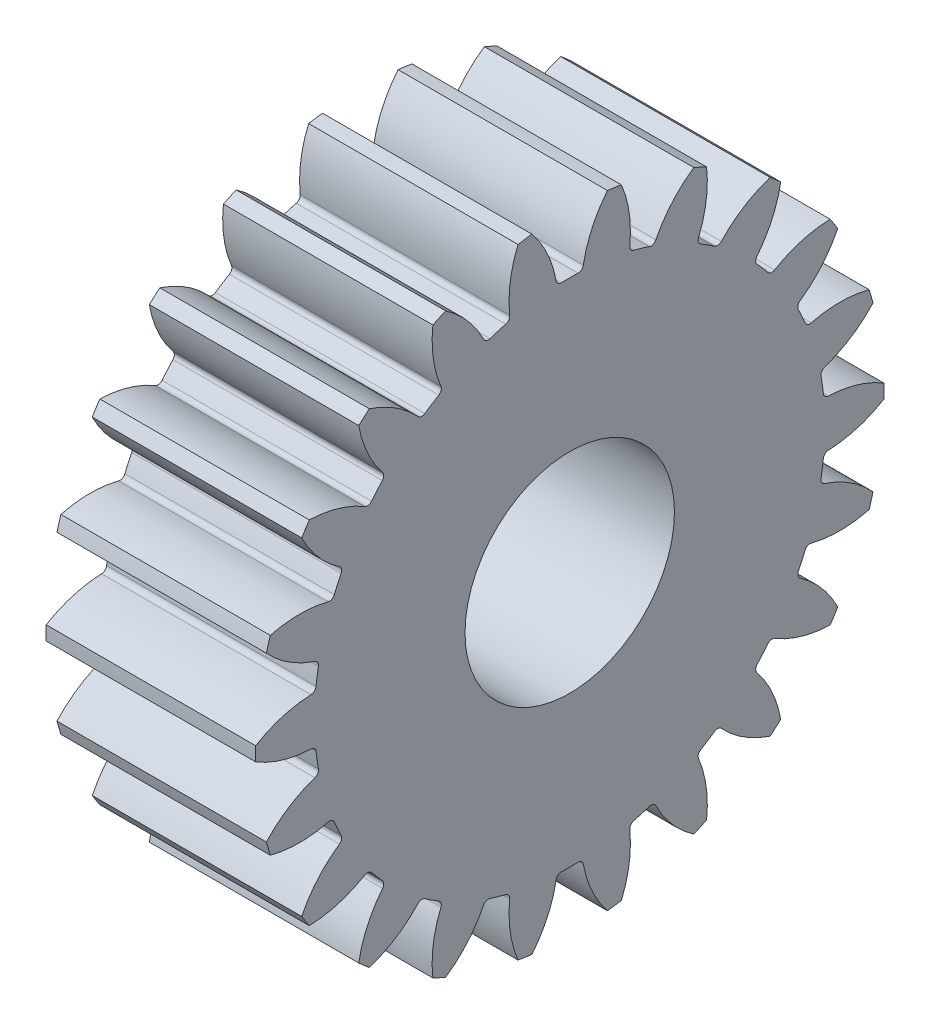
from build123d import *

# Parameters (mm, degrees)
BASPROSKE_W     = 4
BASPROSKE_H     = 6
TOOTHCUT_DEPTH  = 10.38083152
TEETHCUTS_COUNT = 22
TEETHCUTS_ANGLE = 343.636363636
BORSKE_R        = 2
BORE_DEPTH      = 50.0000508
FILLET1_R       = 0.1


with BuildPart() as part:
    # BasProSke → Base-Revolve (revolve)
    with BuildSketch(Plane(origin=(0, 0, 0), x_dir=(1, 0, 0), z_dir=(0, 1, 0)), mode=Mode.PRIVATE) as base_revolve_sk:
        with Locations((2, 3)):
            Rectangle(BASPROSKE_W, BASPROSKE_H)
    revolve(base_revolve_sk.sketch.rotate(Axis((-10, 0, 0), (1, 0, 0)), 180), axis=Axis((-10, 0, 0), (1, 0, 0)))

    # TooCutSke → ToothCut (cut, through all)
    with BuildSketch(Plane(origin=(0, 0, 0), x_dir=(0, 0, -1), z_dir=(1, 0, 0))):
        with BuildLine():
            ThreePointArc((0.245431665, 4.867816687), (0, 4.874), (-0.245431665, 4.867816687))
            ThreePointArc((-0.245431665, 4.867816687), (-0.414371147, 5.458682637), (-0.740152859, 5.979767462))
            ThreePointArc((-0.740152859, 5.979767462), (0, 6.0254), (0.740152859, 5.979767462))
            ThreePointArc((0.740152859, 5.979767462), (0.414371147, 5.458682637), (0.245431665, 4.867816687))
        make_face()
    toothcut = extrude(amount=TOOTHCUT_DEPTH, mode=Mode.SUBTRACT)

    # TeethCuts: ToothCut ×22 about axis
    teethcuts_axis = Axis((-10, 0, 0), (1, 0, 0))
    for i in range(1, TEETHCUTS_COUNT):
        add(toothcut.rotate(teethcuts_axis, i * TEETHCUTS_ANGLE / (TEETHCUTS_COUNT - 1)), mode=Mode.SUBTRACT)

    # BorSke → Bore (cut, symmetric)
    with BuildSketch(Plane(origin=(0, 0, 0), x_dir=(0, 0, -1), z_dir=(1, 0, 0))):
        with Locations(Location((0, 0, 0), (0, 0, 180))):
            Circle(BORSKE_R)
    extrude(amount=BORE_DEPTH, both=True, mode=Mode.SUBTRACT)

    # Fillet1
    fillet1_edges = [part.edges().sort_by_distance(p)[0] for p in [
        (2, 4.867816687, -0.245431665),
        (2, -0.44982902, 4.8531979),
        (2, -0.935696069, 4.783340764),
        (2, 0.935696069, 4.783340764),
        (2, 0.44982902, 4.8531979),
        (2, 2.245416628, 4.325965808),
        (2, 1.798911637, 4.529877804),
        (2, 4.867816687, 0.245431665),
        (2, 4.227758361, 2.425270137),
        (2, 3.962377609, 2.838210648),
        (2, 3.373226885, 3.518126829),
        (2, 3.002257132, 3.83957395),
        (2, -4.867816687, 0.245431665),
        (2, -4.867816687, -0.245431665),
        (2, -4.601489817, 1.6069124),
        (2, -4.739781999, 1.135932483),
        (2, -3.962377609, 2.838210648),
        (2, -4.227758361, 2.425270137),
        (2, -1.798911637, 4.529877804),
        (2, -2.245416628, 4.325965808),
        (2, -3.002257132, 3.83957395),
        (2, -3.373226885, 3.518126829),
        (2, -3.373226885, -3.518126829),
        (2, -3.002257132, -3.83957395),
        (2, -2.245416628, -4.325965808),
        (2, -1.798911637, -4.529877804),
        (2, -0.935696069, -4.783340764),
        (2, -0.44982902, -4.8531979),
        (2, -4.227758361, -2.425270137),
        (2, -3.962377609, -2.838210648),
        (2, -4.739781999, -1.135932483),
        (2, -4.601489817, -1.6069124),
        (2, 3.002257132, -3.83957395),
        (2, 3.373226885, -3.518126829),
        (2, 3.962377609, -2.838210648),
        (2, 4.227758361, -2.425270137),
        (2, 4.601489817, -1.6069124),
        (2, 4.739781999, -1.135932483),
        (2, 1.798911637, -4.529877804),
        (2, 2.245416628, -4.325965808),
        (2, 0.44982902, -4.8531979),
        (2, 0.935696069, -4.783340764),
        (2, 4.739781999, 1.135932483),
        (2, 4.601489817, 1.6069124),
    ]]
    fillet(fillet1_edges, radius=FILLET1_R)


solid = part.part
